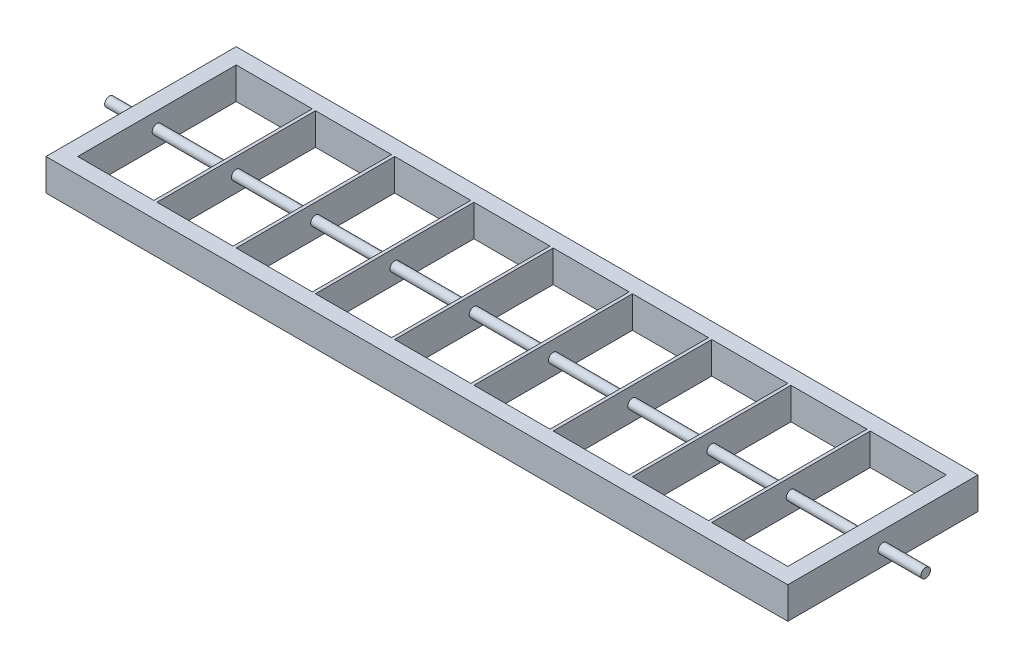
from build123d import *

# Parameters (mm, degrees)
SKETCH1_W                = 468
SKETCH1_H                = 120
SKETCH1_W_2              = 448
SKETCH1_H_2              = 100
BOSS_EXTRUDE1_DEPTH      = 20
SKETCH2_R                = 3
BOSS_EXTRUDE2_DEPTH      = 20
BOSS_EXTRUDE2_DEPTH_BACK = 495
SKETCH4_W                = 2
SKETCH4_H                = 20
BOSS_EXTRUDE3_DEPTH      = 100


with BuildPart() as part:
    # Sketch1 → Boss-Extrude1 (new body)
    with BuildSketch(Plane(origin=(0, 0, 0), x_dir=(1, 0, 0), z_dir=(0, 1, 0))):
        Rectangle(SKETCH1_W, SKETCH1_H)
        Rectangle(SKETCH1_W_2, SKETCH1_H_2, mode=Mode.SUBTRACT)
    extrude(amount=BOSS_EXTRUDE1_DEPTH)

    # Sketch2 → Boss-Extrude2 (add, two sides)
    with BuildSketch(Plane.ZY.offset(234)) as boss_extrude2_sk:
        with Locations((0, 10)):
            Circle(SKETCH2_R)
    extrude(amount=BOSS_EXTRUDE2_DEPTH)
    extrude(boss_extrude2_sk.sketch, amount=-BOSS_EXTRUDE2_DEPTH_BACK)

    # Sketch4 → Boss-Extrude3 (add)
    with BuildSketch(Plane(origin=(0, 0, 50), x_dir=(-1, 0, 0), z_dir=(0, 0, -1))):
        with Locations((-125, 10)):
            Rectangle(SKETCH4_W, SKETCH4_H)
        with Locations((-75, 10)):
            Rectangle(SKETCH4_W, SKETCH4_H)
        with Locations((-25, 10)):
            Rectangle(SKETCH4_W, SKETCH4_H)
        with Locations((25, 10)):
            Rectangle(SKETCH4_W, SKETCH4_H)
        with Locations((75, 10)):
            Rectangle(SKETCH4_W, SKETCH4_H)
        with Locations((125, 10)):
            Rectangle(SKETCH4_W, SKETCH4_H)
        with Locations((175, 10)):
            Rectangle(SKETCH4_W, SKETCH4_H)
        with Locations((-175, 10)):
            Rectangle(SKETCH4_W, SKETCH4_H)
    extrude(amount=BOSS_EXTRUDE3_DEPTH)


solid = part.part
